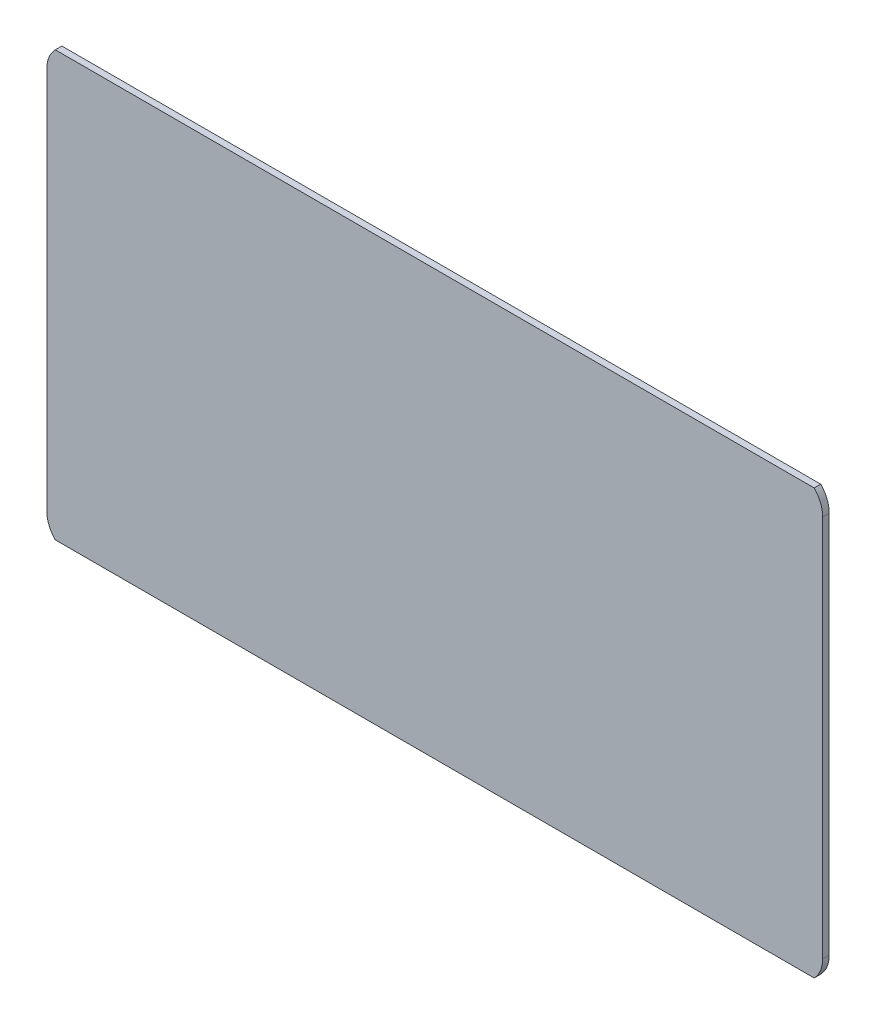
from build123d import *

# Parameters (mm, degrees)
CROQUIS1_W            = 130.24
CROQUIS1_H            = 71.24
BASE_DEPTH            = 1.1
CROQUIS2_W            = 139.816855756
CROQUIS2_H            = 82.895369025
CORTAR_EXTRUIR1_DEPTH = 1.4


with BuildPart() as part:
    # Croquis1 → Base (new body)
    with BuildSketch(Plane.XY):
        with Locations((65.12, -35.62)):
            Rectangle(CROQUIS1_W, CROQUIS1_H)
    extrude(amount=BASE_DEPTH)

    # Croquis2 → Cortar-Extruir1 (cut)
    with BuildSketch(Plane.XY.offset(1.1)):
        with Locations((63.677698172, -34.191443632)):
            Rectangle(CROQUIS2_W, CROQUIS2_H)
        with BuildLine():
            Line((5, 1.5), (125.24, 1.5))
            ThreePointArc((125.24, 1.5), (128.775533906, 0.035533906), (130.24, -3.5))
            Line((130.24, -3.5), (130.24, -67.74))
            ThreePointArc((130.24, -67.74), (128.775533906, -71.275533906), (125.24, -72.74))
            Line((125.24, -72.74), (5, -72.74))
            ThreePointArc((5, -72.74), (1.464466094, -71.275533906), (0, -67.74))
            Line((0, -67.74), (0, -3.5))
            ThreePointArc((0, -3.5), (1.464466094, 0.035533906), (5, 1.5))
        make_face(mode=Mode.SUBTRACT)
    extrude(amount=-CORTAR_EXTRUIR1_DEPTH, mode=Mode.SUBTRACT)


solid = part.part
